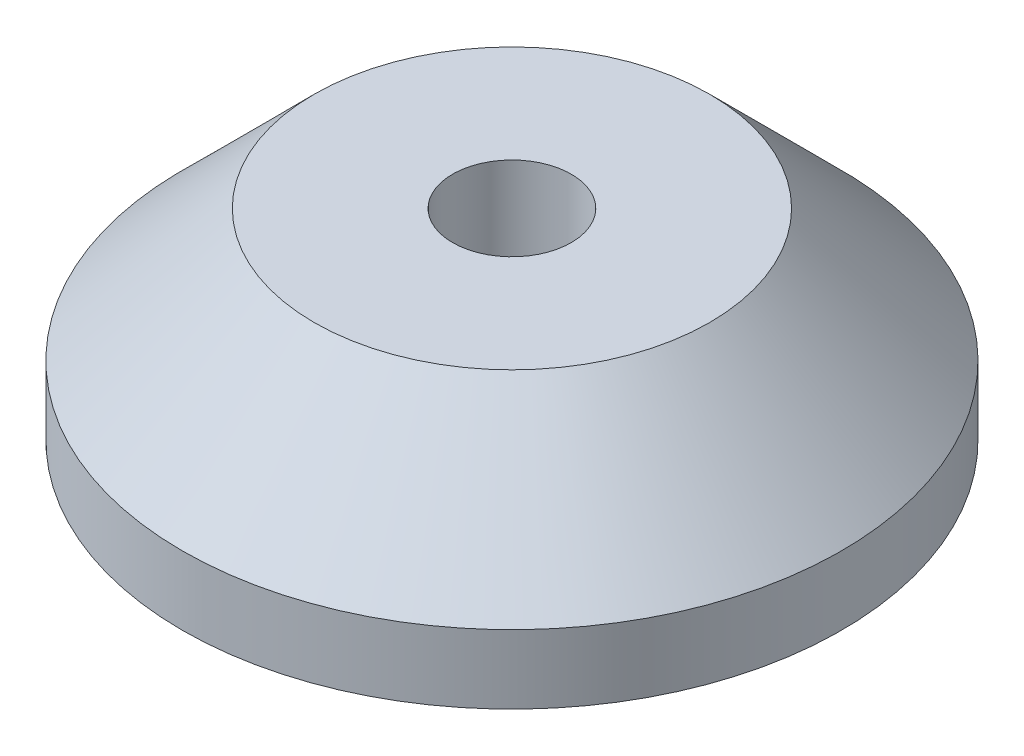
from build123d import *

# Parameters (mm, degrees)
SKETCH1_R           = 31.75
SKETCH1_R_2         = 12.827
BOSS_EXTRUDE1_DEPTH = 5.1054
SKETCH2_R           = 31.75
SKETCH2_R_2         = 5.715
BOSS_EXTRUDE2_DEPTH = 14.224
CHAMFER1_SIZE       = 5.08
CHAMFER2_SIZE       = 12.7


with BuildPart() as part:
    # Sketch1 → Boss-Extrude1 (new body)
    with BuildSketch(Plane(origin=(0, 0, 0), x_dir=(1, 0, 0), z_dir=(0, 1, 0))):
        Circle(SKETCH1_R)
        Circle(SKETCH1_R_2, mode=Mode.SUBTRACT)
    extrude(amount=BOSS_EXTRUDE1_DEPTH)

    # Sketch2 → Boss-Extrude2 (add)
    with BuildSketch(Plane(origin=(0, 5.1054, 0), x_dir=(1, 0, 0), z_dir=(0, 1, 0))):
        Circle(SKETCH2_R)
        Circle(SKETCH2_R_2, mode=Mode.SUBTRACT)
    extrude(amount=BOSS_EXTRUDE2_DEPTH)

    # Chamfer1
    chamfer1_edges = [part.edges().sort_by_distance(p)[0] for p in [
        (-12.827, 0, 0),
    ]]
    chamfer(chamfer1_edges, length=CHAMFER1_SIZE)

    # Chamfer2
    chamfer2_edges = [part.edges().sort_by_distance(p)[0] for p in [
        (-31.75, 19.3294, 0),
    ]]
    chamfer(chamfer2_edges, length=CHAMFER2_SIZE)


solid = part.part
